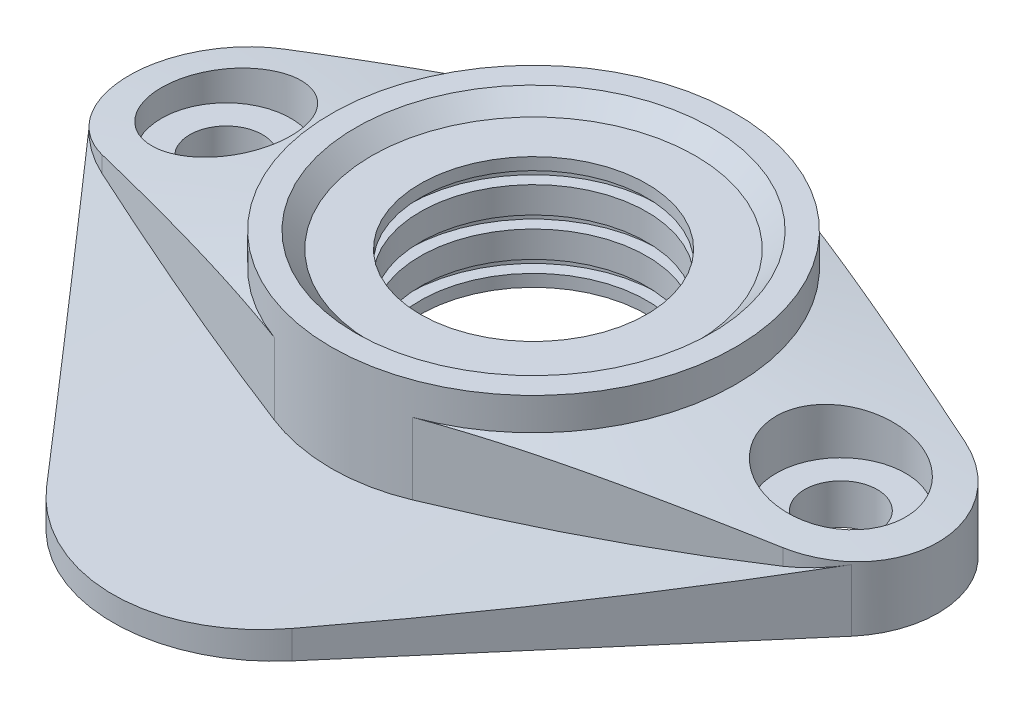
from build123d import *

# Parameters (mm, degrees)
SKETCH_1_R                   = 25
SKETCH_1_R_2                 = 14
EXTRUDE_1_DEPTH              = 16
EXTRUDE_3_REACH              = 40.807
EXTRUDE_4_REACH              = 60.146
EXTRUDE_4_END_RADIUS         = 240
HOLE_WIZARD_M8_1_D           = 9
HOLE_WIZARD_M8_1_CBORE_D     = 16
HOLE_WIZARD_M8_1_CBORE_DEPTH = 11
CUT_EXTRUDE_START            = 16
SKETCH_15_R                  = 22
CUT_EXTRUDE_1_DEPTH          = 2
CUT_EXTRUDE_1_DRAFT          = -45
SKETCH_16_W                  = 1.5
SKETCH_16_H                  = 1.5
PATTERN_LINEAR_1_COUNT       = 3
PATTERN_LINEAR_1_PITCH       = 4.75


with BuildPart() as part:
    # 草图1 → 凸台-拉伸1 (new body)
    with BuildSketch(Plane(origin=(0, 0, 0), x_dir=(1, 0, 0), z_dir=(0, 1, 0))):
        with Locations(Location((0, 0, 0), (0, 0, 270))):
            Circle(SKETCH_1_R)
        with Locations(Location((0, 0, 0), (0, 0, 270))):
            Circle(SKETCH_1_R_2, mode=Mode.SUBTRACT)
    extrude(amount=EXTRUDE_1_DEPTH)

    # 凸台-拉伸3: up to this cone (the profile starts inside it)
    extrude_3_end = Plane(origin=(0, 0, 0), z_dir=(0, -1, 0)).offset(-16.408173518) * Cone(5.671e-06, 855.062315179, 150.770555353, align=(Align.CENTER, Align.CENTER, Align.MIN), mode=Mode.PRIVATE)
    # 草图1<4> → 凸台-拉伸3 (add, up to the surface)
    with BuildSketch(Plane(origin=(0, 0, 0), x_dir=(1, 0, 0), z_dir=(0, 1, 0)), mode=Mode.PRIVATE) as extrude_3_sk1:
        with BuildLine():
            Line((42.105263158, 11.275939624), (8.552631579, 23.491540883))
            ThreePointArc((8.552631579, 23.491540883), (20.479450548, 14.338483367), (25, 0))
            ThreePointArc((25, 0), (20.479450548, -14.338483367), (8.552631579, -23.491540883))
            Line((8.552631579, -23.491540883), (42.105263158, -11.275939624))
            ThreePointArc((42.105263158, -11.275939624), (44.829030594, -9.867337085), (47.10686849, -7.814406331))
            ThreePointArc((47.10686849, -7.814406331), (49.60820541, 3.041310105), (42.105263158, 11.275939624))
        make_face()
    extrude_3_tool1 = extrude(extrude_3_sk1.sketch, amount=EXTRUDE_3_REACH, mode=Mode.PRIVATE) & extrude_3_end
    add(extrude_3_tool1.solids().sort_by_distance((33.391095, 0, 0))[0])
    # 草图1<4> → 凸台-拉伸3 (add, up to the surface)
    with BuildSketch(Plane(origin=(0, 0, 0), x_dir=(1, 0, 0), z_dir=(0, 1, 0)), mode=Mode.PRIVATE) as extrude_3_sk2:
        with BuildLine():
            Line((-8.552631579, 23.491540883), (-42.105263158, 11.275939624))
            ThreePointArc((-42.105263158, 11.275939624), (-49.60820541, 3.041310105), (-47.10686849, -7.814406331))
            ThreePointArc((-47.10686849, -7.814406331), (-44.829030594, -9.867337085), (-42.105263158, -11.275939624))
            Line((-42.105263158, -11.275939624), (-8.552631579, -23.491540883))
            ThreePointArc((-8.552631579, -23.491540883), (-25, 0), (-8.552631579, 23.491540883))
        make_face()
    extrude_3_tool2 = extrude(extrude_3_sk2.sketch, amount=EXTRUDE_3_REACH, mode=Mode.PRIVATE) & extrude_3_end
    add(extrude_3_tool2.solids().sort_by_distance((-33.391095, 0, 0))[0])

    # 凸台-拉伸4: up to this cylinder (the profile starts outside it)
    extrude_4_end = Plane(origin=(0, 243, 31.3806), z_dir=(0, 0, 1)) * Cylinder(EXTRUDE_4_END_RADIUS, 601.292, mode=Mode.PRIVATE)
    # 草图1<7> → 凸台-拉伸4 (add, up to the surface)
    with BuildSketch(Plane(origin=(0, 0, 0), x_dir=(1, 0, 0), z_dir=(0, 1, 0)), mode=Mode.PRIVATE) as extrude_4_sk1:
        with BuildLine():
            ThreePointArc((-42.105263158, -11.275939624), (-44.829030594, -9.867337085), (-47.10686849, -7.814406331))
            Line((-47.10686849, -7.814406331), (-15.178114149, -45.024010552))
            ThreePointArc((-15.178114149, -45.024010552), (0, -52), (15.178114149, -45.024010552))
            Line((15.178114149, -45.024010552), (47.10686849, -7.814406331))
            ThreePointArc((47.10686849, -7.814406331), (44.829030594, -9.867337085), (42.105263158, -11.275939624))
            Line((42.105263158, -11.275939624), (8.552631579, -23.491540883))
            ThreePointArc((8.552631579, -23.491540883), (0, -25), (-8.552631579, -23.491540883))
            Line((-8.552631579, -23.491540883), (-42.105263158, -11.275939624))
        make_face()
    extrude_4_tool1 = extrude(extrude_4_sk1.sketch, amount=EXTRUDE_4_REACH, mode=Mode.PRIVATE) - extrude_4_end
    add(extrude_4_tool1.solids().sort_by_distance((0, 0, 31.3806))[0])

    # M8 六角头螺栓的柱形沉头孔1 (through all)
    with Locations(Plane(origin=(0, 16, 0), x_dir=(1, 0, 0), z_dir=(0, 1, 0))):
        with Locations((-38, 0)):
            hole_wizard_m8_1 = CounterBoreHole(HOLE_WIZARD_M8_1_D / 2, HOLE_WIZARD_M8_1_CBORE_D / 2, HOLE_WIZARD_M8_1_CBORE_DEPTH)

    # 镜向1: M8 六角头螺栓的柱形沉头孔1 across plane
    add(hole_wizard_m8_1.mirror(Plane(origin=(0, 0, 0), x_dir=(0, 0, 1), z_dir=(1, 0, 0))), mode=Mode.SUBTRACT)


with BuildPart() as cut_extrude_1_tool:
    # 草图15 → 切除-拉伸1 (with draft: the straight prism first)
    with BuildSketch(Plane(origin=(0, 0, 0), x_dir=(1, 0, 0), z_dir=(0, 1, 0)).offset(CUT_EXTRUDE_START)):
        Circle(SKETCH_15_R)
    extrude(amount=-CUT_EXTRUDE_1_DEPTH)
    # 切除-拉伸1: the draft: its side faces are tilted about the plane it starts from
    cut_extrude_1_sides = [cut_extrude_1_tool.faces().sort_by_distance(p)[0] for p in [
        (-22, 15, 0),
    ]]
    draft(cut_extrude_1_sides, Plane(origin=(0, 0, 0), x_dir=(1, 0, 0), z_dir=(0, 1, 0)).offset(CUT_EXTRUDE_START), CUT_EXTRUDE_1_DRAFT)


with BuildPart() as part_1:
    add(part.part)

    # 切除-拉伸1: cut by cut_extrude_1_tool
    add(cut_extrude_1_tool.part, mode=Mode.SUBTRACT)

    # 草图16 → 切除-旋转5 (revolve, cut)
    with BuildSketch(Plane.XY, mode=Mode.PRIVATE) as cut_revolve_5_sk:
        with Locations((14.75, 11.75)):
            Rectangle(SKETCH_16_W, SKETCH_16_H)
    cut_revolve_5 = revolve(cut_revolve_5_sk.sketch.rotate(Axis((0, 21.806549083, 0), (0, -1, 0)), 90), axis=Axis((0, 21.806549083, 0), (0, -1, 0)), mode=Mode.SUBTRACT)

    # 阵列(线性)1: 切除-旋转5 ×3
    with Locations(*[(0, -i * PATTERN_LINEAR_1_PITCH, 0) for i in range(1, PATTERN_LINEAR_1_COUNT)]):
        add(cut_revolve_5, mode=Mode.SUBTRACT)


solid = part_1.part
